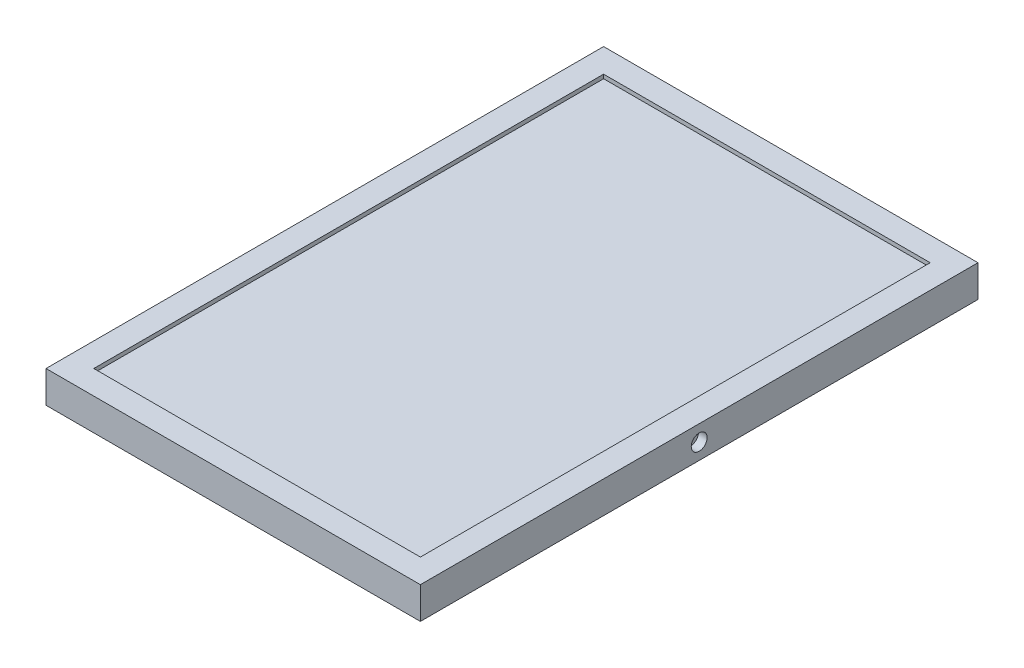
from build123d import *

# Parameters (mm, degrees)
SKETCH1_W                = 235
SKETCH1_H                = 350
SKETCH1_W_2              = 205
SKETCH1_H_2              = 320
BOSS_EXTRUDE1_DEPTH      = 20
BOSS_EXTRUDE2_START      = 15
SKETCH1_2_W              = 205
SKETCH1_2_H              = 320
BOSS_EXTRUDE2_DEPTH      = 2.5
BOSS_EXTRUDE2_DEPTH_BACK = 2.5
SKETCH2_W                = 40
SKETCH2_H                = 50
BOSS_EXTRUDE3_DEPTH      = 12.5
SKETCH3_R                = 5
CUT_EXTRUDE1_DEPTH       = 5.5
CUT_EXTRUDE2_START       = -235
SKETCH3_3_R              = 5
CUT_EXTRUDE2_DEPTH       = 5.5


with BuildPart() as part:
    # Sketch1 → Boss-Extrude1 (new body)
    with BuildSketch(Plane(origin=(0, 0, 0), x_dir=(1, 0, 0), z_dir=(0, 1, 0))):
        Rectangle(SKETCH1_W, SKETCH1_H)
        Rectangle(SKETCH1_W_2, SKETCH1_H_2, mode=Mode.SUBTRACT)
    extrude(amount=BOSS_EXTRUDE1_DEPTH)

    # Sketch1_2 → Boss-Extrude2 (add, two sides)
    with BuildSketch(Plane(origin=(0, 0, 0), x_dir=(1, 0, 0), z_dir=(0, 1, 0)).offset(BOSS_EXTRUDE2_START)) as boss_extrude2_sk:
        Rectangle(SKETCH1_2_W, SKETCH1_2_H)
    extrude(amount=BOSS_EXTRUDE2_DEPTH)
    extrude(boss_extrude2_sk.sketch, amount=-BOSS_EXTRUDE2_DEPTH_BACK)

    # Sketch2 → Boss-Extrude3 (add)
    with BuildSketch(Plane.XZ.offset(-12.5)):
        with Locations((51.25, 0)):
            Rectangle(SKETCH2_W, SKETCH2_H)
    extrude(amount=BOSS_EXTRUDE3_DEPTH)

    # Sketch3 → Cut-Extrude1 (cut)
    with BuildSketch(Plane.ZY.offset(117.5)):
        with Locations((0, 10)):
            Circle(SKETCH3_R)
    extrude(amount=-CUT_EXTRUDE1_DEPTH, mode=Mode.SUBTRACT)

    # Sketch3_3 → Cut-Extrude2 (cut)
    with BuildSketch(Plane.ZY.offset(117.5).offset(CUT_EXTRUDE2_START)):
        with Locations((0, 10)):
            Circle(SKETCH3_3_R)
    extrude(amount=CUT_EXTRUDE2_DEPTH, mode=Mode.SUBTRACT)


solid = part.part
